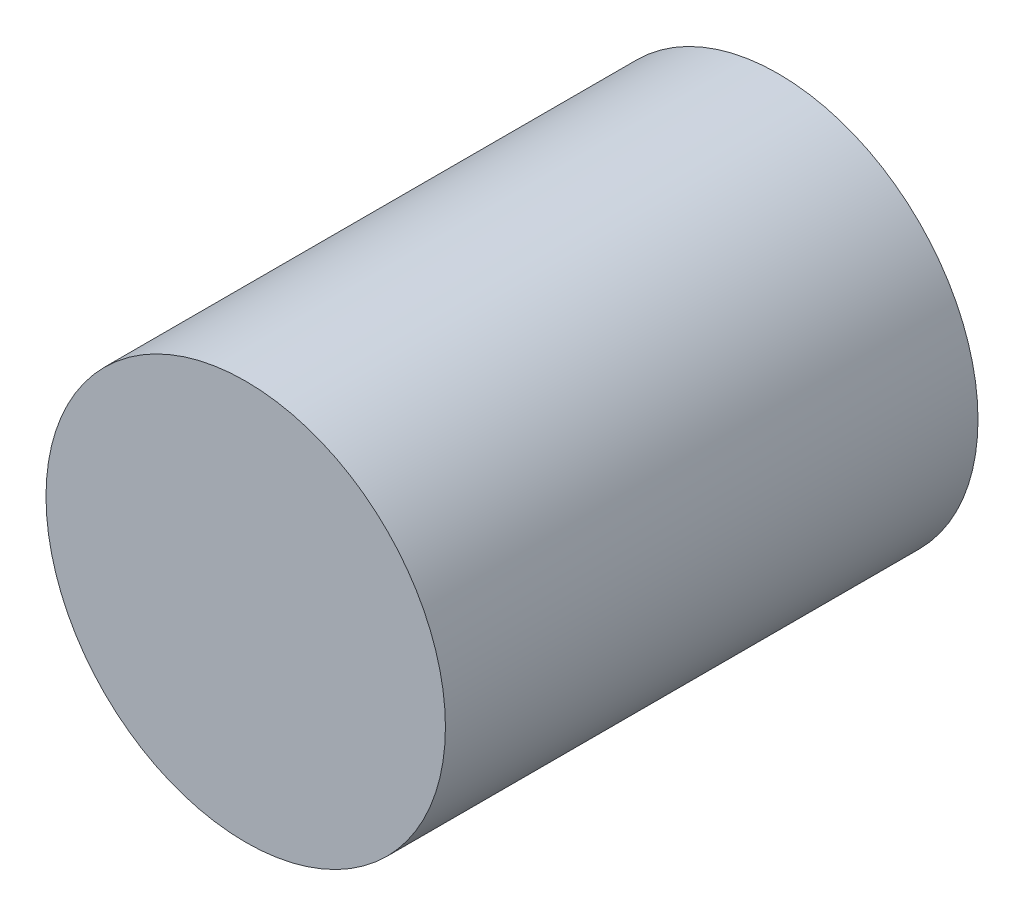
from build123d import *

# Parameters (mm, degrees)
SKETCH1_R           = 1.5
BOSS_EXTRUDE1_DEPTH = 4


with BuildPart() as part:
    # Sketch1 → Boss-Extrude1 (new body)
    with BuildSketch(Plane.XY):
        Circle(SKETCH1_R)
    extrude(amount=BOSS_EXTRUDE1_DEPTH)


solid = part.part
